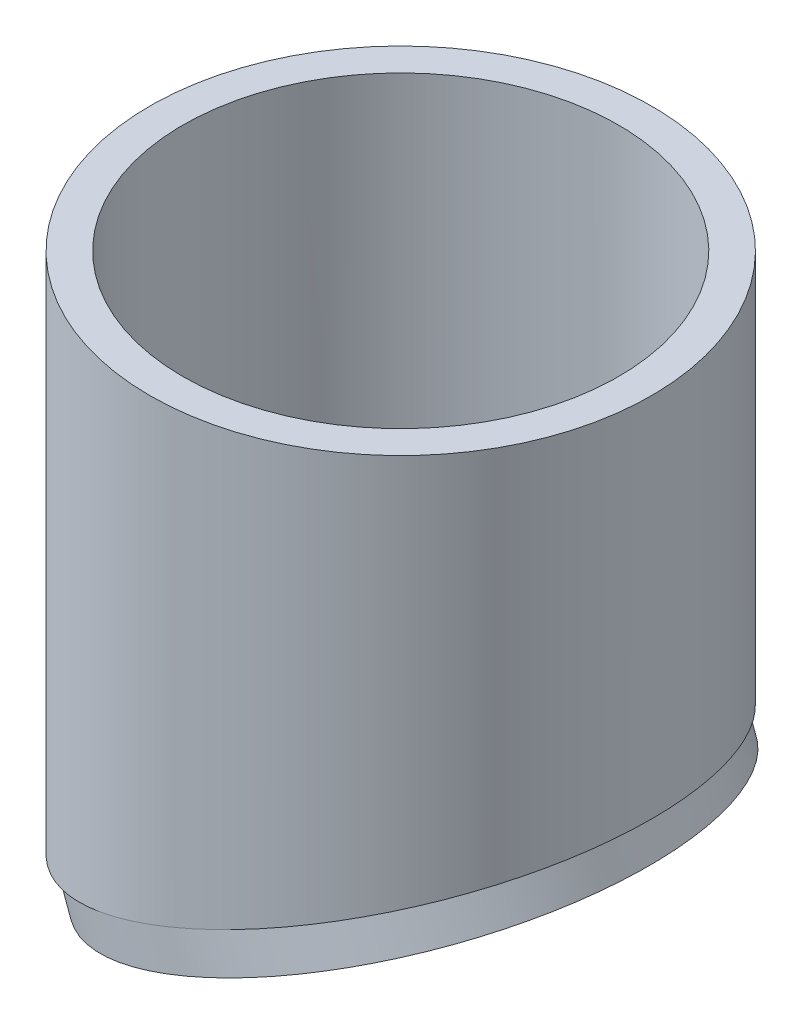
from build123d import *

# Parameters (mm, degrees)
SKETCH1_R                = 83.4771
SKETCH1_R_2              = 72.5043
BOSS_EXTRUDE1_DEPTH      = 152.4
BOSS_EXTRUDE1_DEPTH_BACK = 50.8
SKETCH4_W                = 203.2
SKETCH4_H                = 203.2
CUT_EXTRUDE1_DEPTH       = 152.4
SKETCH5_R                = 83.4771
SKETCH5_RX               = 77.157464469
SKETCH5_RY               = 72.5043
BOSS_EXTRUDE3_DEPTH      = 12.7


with BuildPart() as part:
    # Sketch1 → Boss-Extrude1 (new body, two sides)
    with BuildSketch(Plane(origin=(0, 0, 0), x_dir=(1, 0, 0), z_dir=(0, 1, 0))) as boss_extrude1_sk:
        Circle(SKETCH1_R)
        Circle(SKETCH1_R_2, mode=Mode.SUBTRACT)
    extrude(amount=BOSS_EXTRUDE1_DEPTH)
    extrude(boss_extrude1_sk.sketch, amount=-BOSS_EXTRUDE1_DEPTH_BACK)

    # Sketch4 → Cut-Extrude1 (cut)
    with BuildSketch(Plane(origin=(0, 0, 0), x_dir=(0, 0, -1), z_dir=(-0.342020143, 0.939692621, 0))):
        Rectangle(SKETCH4_W, SKETCH4_H)
    extrude(amount=-CUT_EXTRUDE1_DEPTH, mode=Mode.SUBTRACT)

    # Sketch5 → Boss-Extrude3 (add)
    with BuildSketch(Plane(origin=(0, 0, 0), x_dir=(0, 0, -1), z_dir=(-0.342020143, 0.939692621, 0))):
        Circle(SKETCH5_R)
        with Locations(Location((0, 0), (0, 0, -90))):
            Ellipse(SKETCH5_RX, SKETCH5_RY, mode=Mode.SUBTRACT)
    extrude(amount=-BOSS_EXTRUDE3_DEPTH)


solid = part.part
